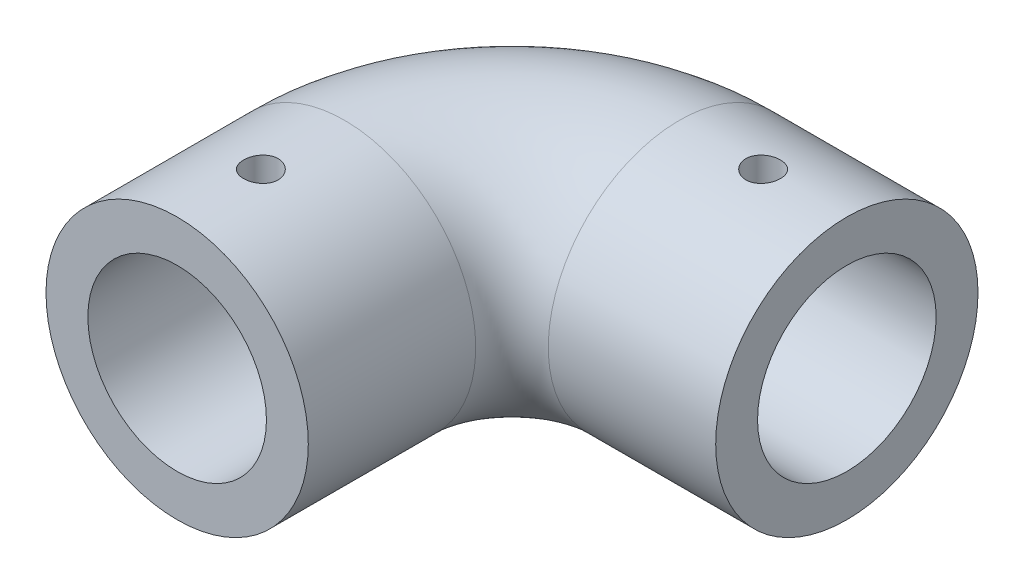
from build123d import *

# Parameters (mm, degrees)
SKETCH2_R          = 23.5
SKETCH2_R_2        = 16
SKETCH3_R          = 3.1
CUT_EXTRUDE1_DEPTH = 40


with BuildPart() as part:
    # Sweep8: sweep along a path in Sketch1
    with BuildLine(Plane(origin=(0, 0, 0), x_dir=(1, 0, 0), z_dir=(0, 1, 0))) as sweep8_path:
        Line((0, 0), (0, 30))
        ThreePointArc((0, 30), (8.786796564, 51.213203436), (30, 60))
        Line((30, 60), (60, 60))
    # Sketch2 → Sweep8 (sweep)
    with BuildSketch(Plane.XY):
        Circle(SKETCH2_R)
        Circle(SKETCH2_R_2, mode=Mode.SUBTRACT)
    sweep(path=sweep8_path.line)

    # Sketch3 → Cut-Extrude1 (cut)
    with BuildSketch(Plane(origin=(0, 0, 0), x_dir=(1, 0, 0), z_dir=(0, 1, 0))):
        with Locations((0, 15)):
            Circle(SKETCH3_R)
        with Locations((45, 60)):
            Circle(SKETCH3_R)
    extrude(amount=CUT_EXTRUDE1_DEPTH, mode=Mode.SUBTRACT)


solid = part.part
